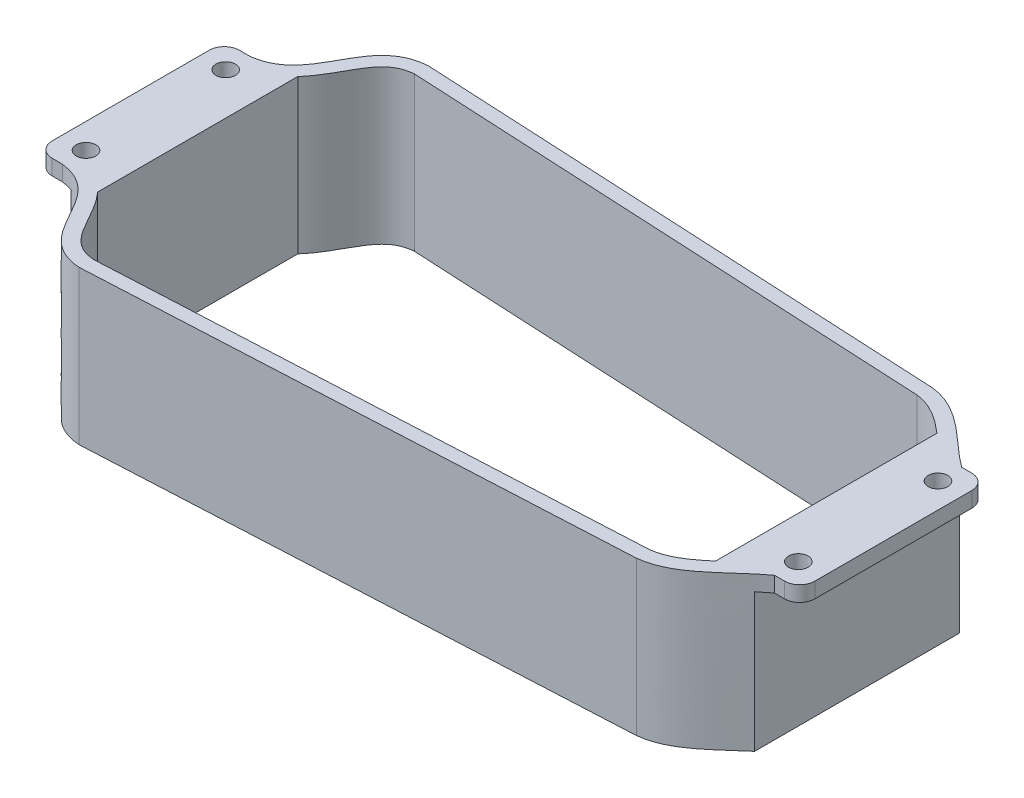
from build123d import *

# Parameters (mm, degrees)
SKETCH1_R           = 3.5
BOSS_EXTRUDE2_DEPTH = 55
SKETCH7_W           = 68.999652055
SKETCH7_H           = 50.415620377
CUT_EXTRUDE5_DEPTH  = 13
SKETCH19_W          = 74.859412742
SKETCH19_H          = 60.725118028
CUT_EXTRUDE7_DEPTH  = 13
CUT_EXTRUDE9_DEPTH  = 55


with BuildPart() as part:
    # Sketch1 → Boss-Extrude2 (new body)
    with BuildSketch(Plane(origin=(0, 0, 0), x_dir=(1, 0, 0), z_dir=(0, 1, 0))):
        with BuildLine():
            Line((-77.297393365, -66.943127962), (112.637979465, -57.343127962))
            add(Edge.make_bspline(
                [(112.637979465, -57.343127962), (125.082628436, -56.027724614), (133.287763268, -44.662014668), (142.702606635, -37.943127962)],
                knots=[0, 0, 0, 0, 1, 1, 1, 1], degree=3))
            Line((142.702606635, -37.943127962), (146.202606635, -37.943127962))
            Line((146.202606635, -37.943127962), (146.302606635, -37.943127962))
            ThreePointArc((146.302606635, -37.943127962), (150.120983253, -36.36150458), (151.702606635, -32.543127962))
            Line((151.702606635, -32.543127962), (151.702606635, 23.656872038))
            ThreePointArc((151.702606635, 23.656872038), (150.120983253, 27.475248656), (146.302606635, 29.056872038))
            Line((146.302606635, 29.056872038), (146.202606635, 29.056872038))
            Line((146.202606635, 29.056872038), (142.702606635, 29.056872038))
            add(Edge.make_bspline(
                [(112.637979465, 48.456872038), (125.082628436, 47.14146869), (133.287763268, 35.775758744), (142.702606635, 29.056872038)],
                knots=[0, 0, 0, 0, 1, 1, 1, 1], degree=3))
            Line((112.637979465, 48.456872038), (-77.297393365, 58.056872038))
            add(Edge.make_bspline(
                [(-77.297393365, 58.056872038), (-97.47829568, 56.558543187), (-92.669908534, 31.299380259), (-112.297393365, 29.056872038)],
                knots=[0, 0, 0, 0, 1, 1, 1, 1], degree=3))
            Line((-112.297393365, 29.056872038), (-115.797393365, 29.056872038))
            Line((-115.797393365, 29.056872038), (-115.897393365, 29.056872038))
            ThreePointArc((-115.897393365, 29.056872038), (-119.715769983, 27.475248656), (-121.297393365, 23.656872038))
            Line((-121.297393365, 23.656872038), (-121.297393365, -32.543127962))
            ThreePointArc((-121.297393365, -32.543127962), (-119.715769983, -36.36150458), (-115.897393365, -37.943127962))
            Line((-115.897393365, -37.943127962), (-115.797393365, -37.943127962))
            Line((-115.797393365, -37.943127962), (-112.297393365, -37.943127962))
            add(Edge.make_bspline(
                [(-77.297393365, -66.943127962), (-97.47829568, -65.444799111), (-92.669908534, -40.185636183), (-112.297393365, -37.943127962)],
                knots=[0, 0, 0, 0, 1, 1, 1, 1], degree=3))
        make_face()
        with Locations((-112.297393365, 20.556872038)):
            Circle(SKETCH1_R, mode=Mode.SUBTRACT)
        with Locations((-112.297393365, -29.443127962)):
            Circle(SKETCH1_R, mode=Mode.SUBTRACT)
        with Locations((142.702606635, -29.443127962)):
            Circle(SKETCH1_R, mode=Mode.SUBTRACT)
        with Locations((142.702606635, 20.556872038)):
            Circle(SKETCH1_R, mode=Mode.SUBTRACT)
    extrude(amount=-BOSS_EXTRUDE2_DEPTH)

    # Sketch7 → Cut-Extrude5 (cut)
    with BuildSketch(Plane.ZY.offset(121.297393365)):
        with Locations((4.333112833, -30.707810189)):
            Rectangle(SKETCH7_W, SKETCH7_H)
    extrude(amount=-CUT_EXTRUDE5_DEPTH, mode=Mode.SUBTRACT)

    # Sketch19 → Cut-Extrude7 (cut)
    with BuildSketch(Plane(origin=(151.702606635, 0, 0), x_dir=(0, 0, -1), z_dir=(1, 0, 0))):
        with Locations((-5.097493458, -35.862559014)):
            Rectangle(SKETCH19_W, SKETCH19_H)
    extrude(amount=-CUT_EXTRUDE7_DEPTH, mode=Mode.SUBTRACT)

    # Sketch24 → Cut-Extrude9 (cut)
    with BuildSketch(Plane(origin=(0, 0, 0), x_dir=(1, 0, 0), z_dir=(0, 1, 0))):
        with BuildLine():
            Line((-97.297393365, 31.372357528), (-97.297393365, -40.258643174))
            add(Edge.make_bspline(
                [(-97.297393365, -40.258643174), (-97.055392699, -40.522543308), (-96.818465561, -40.791519395), (-95.29604309, -42.586141239), (-94.180102109, -44.221795649), (-92.114981147, -47.600331907), (-91.167558943, -49.344344007), (-89.714260063, -51.939679671), (-89.224013692, -52.801383116), (-88.197386212, -54.493312492), (-87.661405753, -55.323638026), (-86.787164869, -56.520642624), (-86.483908233, -56.911472942), (-85.845311529, -57.670997258), (-85.510678135, -58.038515471), (-84.461423347, -59.080983609), (-83.697062972, -59.699960103), (-82.417122679, -60.472101656), (-81.975749173, -60.698816325), (-81.073807536, -61.09027214), (-80.611895531, -61.255932259), (-79.196960523, -61.672670039), (-78.210701758, -61.84358461), (-77.219838786, -61.93282554)],
                knots=[0.352672192, 0.352672192, 0.352672192, 0.352672192, 0.375, 0.375, 0.5, 0.5, 0.625, 0.625, 0.6875, 0.6875, 0.75, 0.75, 0.78125, 0.78125, 0.8125, 0.8125, 0.875, 0.875, 0.90625, 0.90625, 0.9375, 0.9375, 1, 1, 1, 1], degree=3))
            Line((-77.219838786, -61.93282554), (112.240105599, -52.356855361))
            add(Edge.make_bspline(
                [(112.240105599, -52.356855361), (113.717382254, -52.189730891), (115.132971643, -51.8376863), (117.182437857, -51.088035578), (117.853343768, -50.801431656), (119.174145437, -50.165241611), (119.826422425, -49.814165646), (121.732436005, -48.696872923), (122.940710016, -47.866553193), (125.285242411, -46.107289747), (126.421126606, -45.177833586), (127.59402171, -44.178301992), (127.648334729, -44.131926563), (127.702606635, -44.085499704)],
                knots=[0, 0, 0, 0, 0.125, 0.125, 0.1875, 0.1875, 0.25, 0.25, 0.375, 0.375, 0.5, 0.5, 0.506074438, 0.506074438, 0.506074438, 0.506074438], degree=3))
            Line((127.702606635, -44.085499704), (127.702606635, 35.199241787))
            add(Edge.make_bspline(
                [(127.702606635, 35.199241787), (127.656893723, 35.238347374), (126.494699106, 36.231003566), (125.312312668, 37.199657877), (123.548827323, 38.524500877), (122.950515573, 38.954402998), (121.735559113, 39.776761834), (121.118108697, 40.169868377), (119.227839741, 41.28046867), (117.917675896, 41.930280463), (115.836701988, 42.695260765), (115.130607863, 42.912098814), (113.700996756, 43.257880714), (112.975983658, 43.387349472), (112.240105599, 43.470599437)],
                knots=[0.494878569, 0.494878569, 0.494878569, 0.494878569, 0.5, 0.625, 0.625, 0.6875, 0.6875, 0.75, 0.75, 0.875, 0.875, 0.9375, 0.9375, 1, 1, 1, 1], degree=3))
            Line((112.240105599, 43.470599437), (-77.219838786, 53.046569616))
            add(Edge.make_bspline(
                [(-77.219838786, 53.046569616), (-78.226254375, 52.955927957), (-79.213157443, 52.784359124), (-80.65236022, 52.356330798), (-81.126202061, 52.184487982), (-82.053330615, 51.775193987), (-82.497083796, 51.5419399), (-83.346280845, 51.020113337), (-83.751740407, 50.731563524), (-84.52795848, 50.104355813), (-84.899500865, 49.764992502), (-85.964937473, 48.68741183), (-86.589708432, 47.913990928), (-87.747790314, 46.308292885), (-88.280321037, 45.475513671), (-89.301365793, 43.781629681), (-89.789527485, 42.920298168), (-91.239394158, 40.326896414), (-92.188900691, 38.584245442), (-94.255960588, 35.221000735), (-95.371079537, 33.60184943), (-96.859865551, 31.858322069), (-97.076237995, 31.613508704), (-97.297393365, 31.372357528)],
                knots=[0, 0, 0, 0, 0.0625, 0.0625, 0.09375, 0.09375, 0.125, 0.125, 0.15625, 0.15625, 0.1875, 0.1875, 0.25, 0.25, 0.3125, 0.3125, 0.375, 0.375, 0.5, 0.5, 0.625, 0.625, 0.645748558, 0.645748558, 0.645748558, 0.645748558], degree=3))
        make_face()
    extrude(amount=-CUT_EXTRUDE9_DEPTH, mode=Mode.SUBTRACT)


solid = part.part
